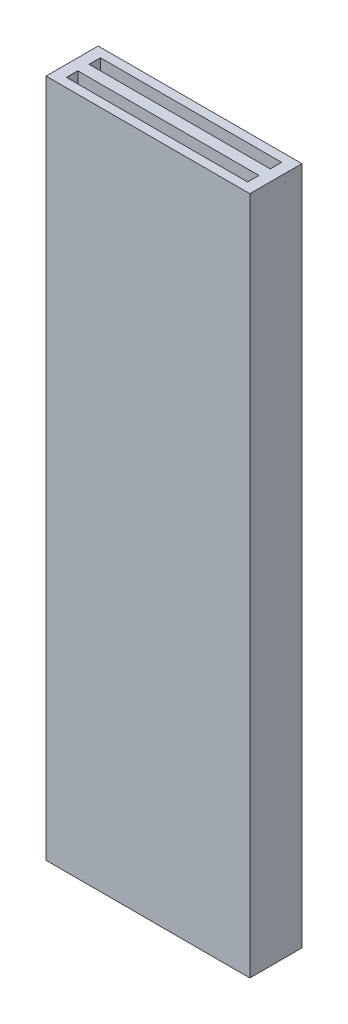
from build123d import *

# Parameters (mm, degrees)
SKETCH1_W           = 9
SKETCH1_H           = 2.3
BOSS_EXTRUDE1_DEPTH = 15
CUT_EXTRUDE1_START  = -31
SKETCH2_W           = 8
SKETCH2_H           = 0.5
CUT_EXTRUDE1_DEPTH  = 32


with BuildPart() as part:
    # Sketch1 → Boss-Extrude1 (new body, symmetric)
    with BuildSketch(Plane(origin=(0, 0, 0), x_dir=(1, 0, 0), z_dir=(0, 1, 0))):
        Rectangle(SKETCH1_W, SKETCH1_H)
    extrude(amount=BOSS_EXTRUDE1_DEPTH, both=True)

    # Sketch2 → Cut-Extrude1 (cut)
    with BuildSketch(Plane(origin=(0, 15, 0), x_dir=(1, 0, 0), z_dir=(0, 1, 0)).offset(CUT_EXTRUDE1_START)):
        with Locations((0, 0.5)):
            Rectangle(SKETCH2_W, SKETCH2_H)
    cut_extrude1 = extrude(amount=CUT_EXTRUDE1_DEPTH, mode=Mode.SUBTRACT)

    # Mirror1: Cut-Extrude1 across plane
    add(cut_extrude1.mirror(Plane.XY), mode=Mode.SUBTRACT)


solid = part.part
